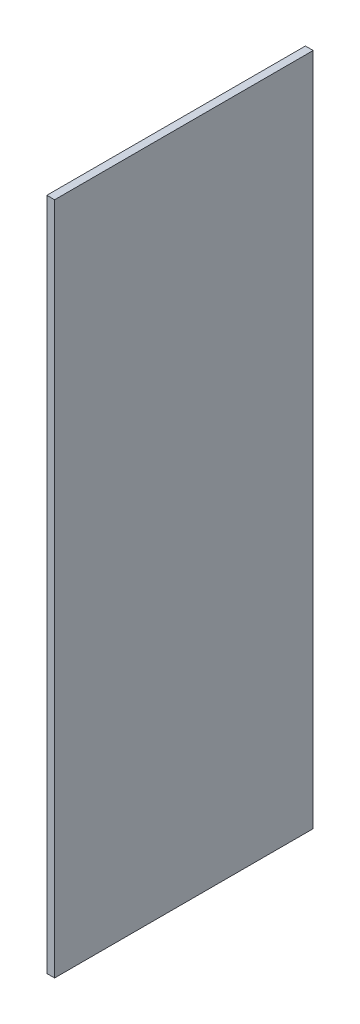
from build123d import *

# Parameters (mm, degrees)
SKETCH_1_W      = 600
SKETCH_1_H      = 1564
EXTRUDE_1_DEPTH = 18


with BuildPart() as part:
    # Эскиз1 → Бобышка-Вытянуть1 (new body)
    with BuildSketch(Plane(origin=(0, 0, 0), x_dir=(0, 0, -1), z_dir=(1, 0, 0))):
        with Locations((300, 782)):
            Rectangle(SKETCH_1_W, SKETCH_1_H)
    extrude(amount=EXTRUDE_1_DEPTH)


solid = part.part
